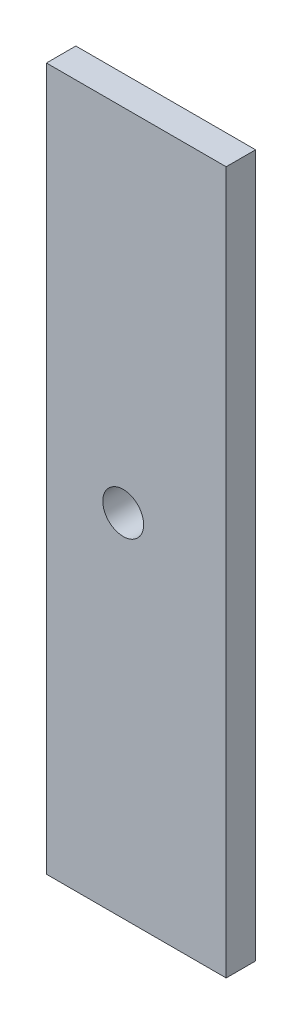
from build123d import *

# Parameters (mm, degrees)
SKETCH1_W           = 110
SKETCH1_H           = 430
SKETCH1_R           = 12.5
BOSS_EXTRUDE1_DEPTH = 18


with BuildPart() as part:
    # Sketch1 → Boss-Extrude1 (new body)
    with BuildSketch(Plane.XY):
        Rectangle(SKETCH1_W, SKETCH1_H)
        with Locations((-8, 0)):
            Circle(SKETCH1_R, mode=Mode.SUBTRACT)
    extrude(amount=BOSS_EXTRUDE1_DEPTH)


solid = part.part
